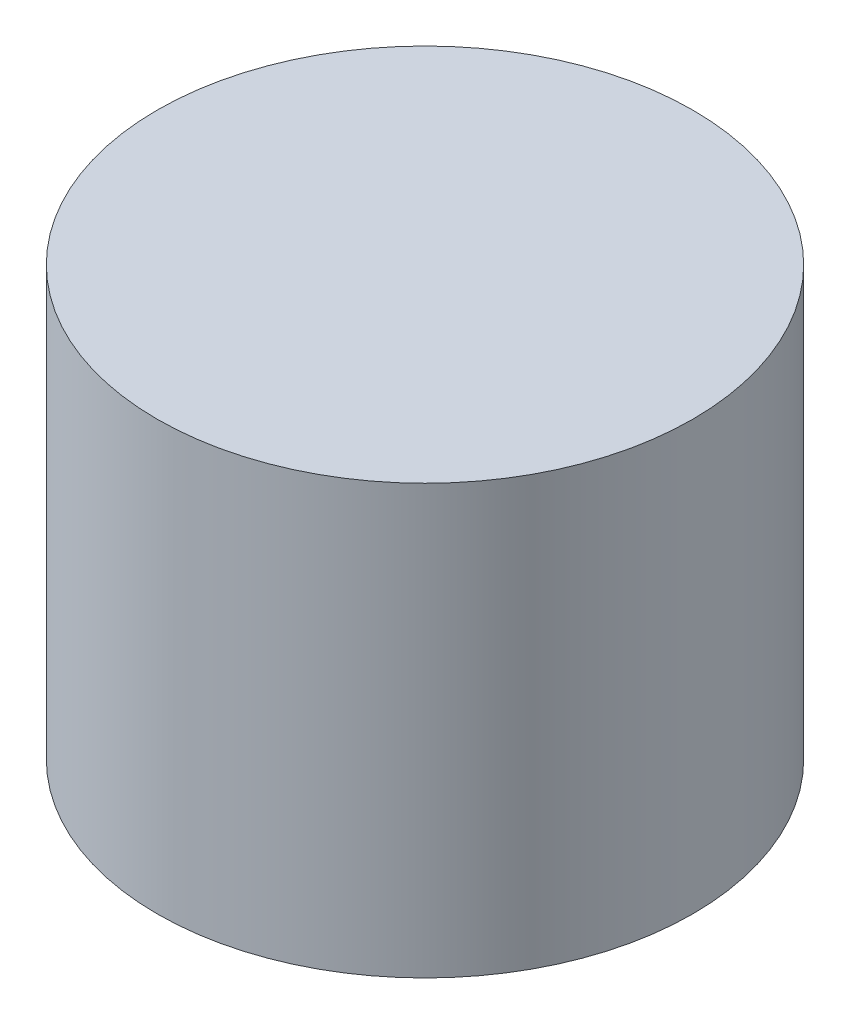
from build123d import *

# Parameters (mm, degrees)
SHOCK_CORD_BUNDLE_PROFILE_R  = 63.5
SHOCK_CORD_BUNDLE_BODY_DEPTH = 101.6


with BuildPart() as part:
    # Shock Cord Bundle Profile → Shock Cord Bundle Body (new body)
    with BuildSketch(Plane(origin=(0, 0, 0), x_dir=(1, 0, 0), z_dir=(0, 1, 0))):
        Circle(SHOCK_CORD_BUNDLE_PROFILE_R)
    extrude(amount=SHOCK_CORD_BUNDLE_BODY_DEPTH)


solid = part.part
